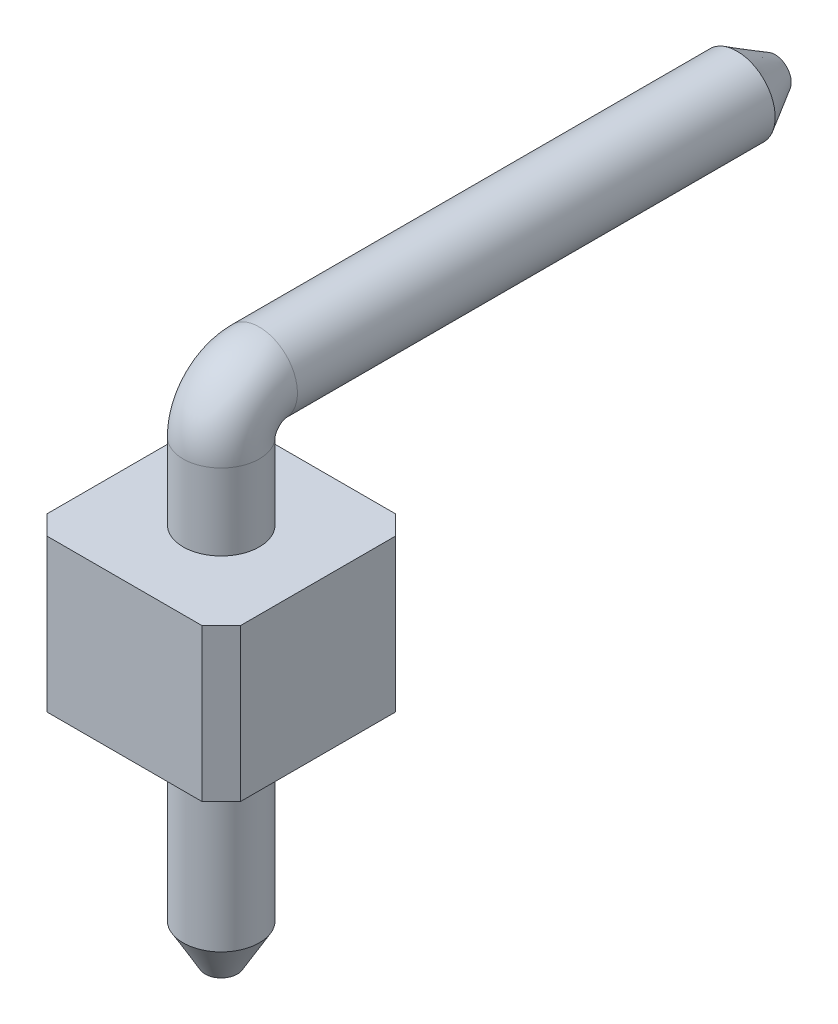
from build123d import *

# Parameters (mm, degrees)
SKETCH1_W           = 2.54
SKETCH1_H           = 2.54
BOSS_EXTRUDE1_DEPTH = 2
CHAMFER1_SIZE       = 0.25
SKETCH3_R           = 0.5
BOSS_EXTRUDE3_DEPTH = 3
CHAMFER3_SIZE       = 0.5
CHAMFER3_SIZE2      = 0.288675135
SKETCH2_R           = 0.5
CHAMFER4_SIZE       = 0.5
CHAMFER4_SIZE2      = 0.288675135


with BuildPart() as part:
    # Sketch1 → Boss-Extrude1 (new body)
    with BuildSketch(Plane(origin=(0, 0, 0), x_dir=(1, 0, 0), z_dir=(0, 1, 0))):
        Rectangle(SKETCH1_W, SKETCH1_H)
    extrude(amount=BOSS_EXTRUDE1_DEPTH)

    # Chamfer1
    chamfer1_edges = [part.edges().sort_by_distance(p)[0] for p in [
        (1.27, 1, 1.27),
        (-1.27, 1, 1.27),
        (-1.27, 1, -1.27),
        (1.27, 1, -1.27),
    ]]
    chamfer(chamfer1_edges, length=CHAMFER1_SIZE)

    # Sketch3 → Boss-Extrude3 (add)
    with BuildSketch(Plane.XZ):
        Circle(SKETCH3_R)
    extrude(amount=BOSS_EXTRUDE3_DEPTH)

    # Chamfer3
    chamfer3_edges = [part.edges().sort_by_distance(p)[0] for p in [
        (-0.5, -3, 0),
    ]]
    chamfer3_side = [part.faces().sort_by_distance(p)[0] for p in [
        (-0.5, -1.5, 0),
    ]]
    chamfer(chamfer3_edges, length=CHAMFER3_SIZE, length2=CHAMFER3_SIZE2, reference=chamfer3_side[0])

    # Sweep1: sweep along a path in Sketch4
    with BuildLine(Plane(origin=(0, 0, 0), x_dir=(0, 0, -1), z_dir=(1, 0, 0))) as sweep1_path:
        Line((0, 2), (0, 3))
        ThreePointArc((0, 3), (0.146446609, 3.353553391), (0.5, 3.5))
        Line((0.5, 3.5), (7.27, 3.5))
    # Sketch2 → Sweep1 (sweep)
    with BuildSketch(Plane(origin=(0, 2, 0), x_dir=(1, 0, 0), z_dir=(0, 1, 0))):
        Circle(SKETCH2_R)
    sweep(path=sweep1_path.line)

    # Chamfer4
    chamfer4_edges = [part.edges().sort_by_distance(p)[0] for p in [
        (-0.5, 3.5, -7.27),
    ]]
    chamfer4_side = [part.faces().sort_by_distance(p)[0] for p in [
        (-0.5, 3.5, -3.885),
    ]]
    chamfer(chamfer4_edges, length=CHAMFER4_SIZE, length2=CHAMFER4_SIZE2, reference=chamfer4_side[0])


solid = part.part
